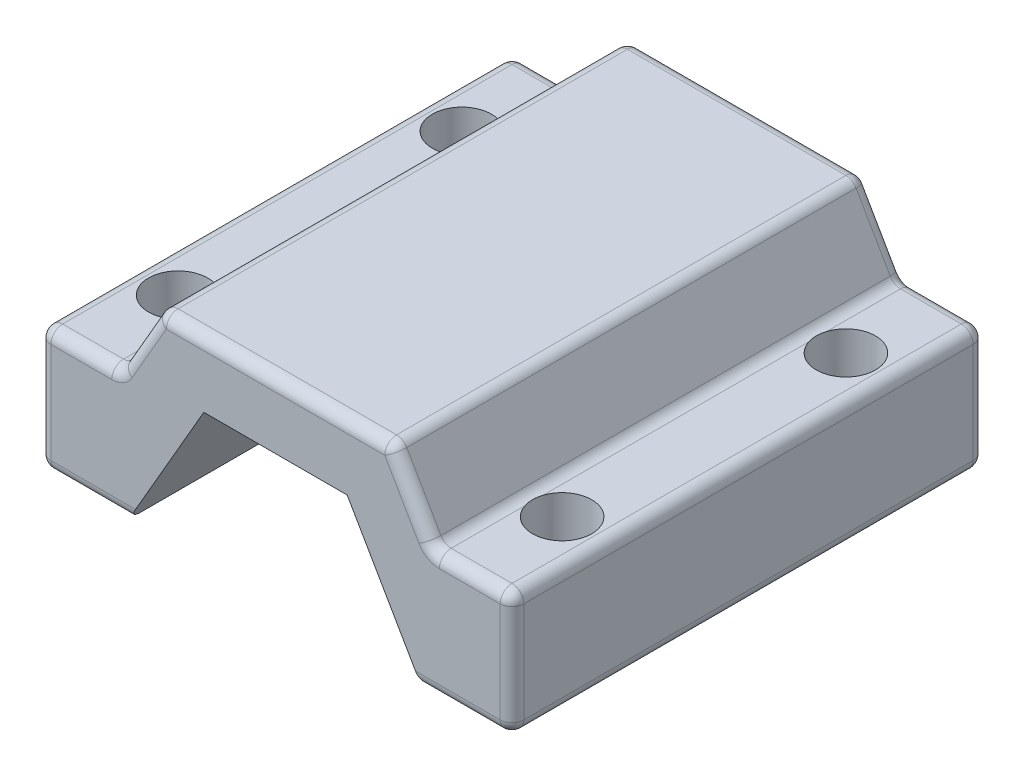
from build123d import *

# Parameters (mm, degrees)
BASE_EXTRUDE_DEPTH                               = 254
CUT_EXTRUDE3_DEPTH                               = 255
FILLET1_R                                        = 6.35
CBORE_FOR_3_4_SOCKET_HEAD_CAP_SCREW1_D           = 19.84248
CBORE_FOR_3_4_SOCKET_HEAD_CAP_SCREW1_CBORE_D     = 31.75
CBORE_FOR_3_4_SOCKET_HEAD_CAP_SCREW1_CBORE_DEPTH = 63.5


with BuildPart() as part:
    # Sketch1 → Base-Extrude (new body)
    with BuildSketch(Plane.XY):
        Polygon((-38.494829198, 73.025), (38.494829198, 73.025), (78.822745501, 3.175), (127, 3.175), (127, 107.95), (-127, 107.95), (-127, 3.175), (-78.822745501, 3.175), align=None)
    extrude(amount=BASE_EXTRUDE_DEPTH)

    # Sketch4 → Cut-Extrude3 (cut, through all)
    with BuildSketch(Plane.XY.offset(254)):
        Polygon((-127, 69.85), (-127, 107.95), (-62.324961559, 107.95), (-84.322006815, 69.85), align=None)
    cut_extrude3 = extrude(amount=-CUT_EXTRUDE3_DEPTH, mode=Mode.SUBTRACT)

    # Mirror1: Cut-Extrude3 across plane
    add(cut_extrude3.mirror(Plane(origin=(0, 0, 0), x_dir=(0, 0, 1), z_dir=(1, 0, 0))), mode=Mode.SUBTRACT)

    # Fillet1
    fillet1_edges = [part.edges().sort_by_distance(p)[0] for p in [
        (127, 36.5125, 0),
        (102.911372751, 3.175, 0),
        (-127, 36.5125, 254),
        (-127, 3.175, 127),
        (127, 3.175, 127),
        (-102.911372751, 3.175, 254),
        (-73.323484187, 88.9, 254),
        (-62.324961559, 107.95, 127),
        (-105.661003408, 69.85, 254),
        (-84.322006815, 69.85, 127),
        (-127, 69.85, 127),
        (-73.323484187, 88.9, 0),
        (-105.661003408, 69.85, 0),
        (0, 107.95, 0),
        (0, 107.95, 254),
        (102.911372751, 3.175, 254),
        (62.324961559, 107.95, 127),
        (105.661003408, 69.85, 0),
        (127, 69.85, 127),
        (73.323484187, 88.9, 0),
        (84.322006815, 69.85, 127),
        (73.323484187, 88.9, 254),
        (105.661003408, 69.85, 254),
        (127, 36.5125, 254),
        (-102.911372751, 3.175, 0),
        (-127, 36.5125, 0),
    ]]
    fillet(fillet1_edges, radius=FILLET1_R)

    # CBORE for 3/4 Socket Head Cap Screw1 (through all)
    with Locations(Plane(origin=(32.15140412, 107.95, 73.186569829), x_dir=(-1, 0, 0), z_dir=(0, 1, 0))):
        with Locations((135.27540412, 130.013430171), (135.27540412, -22.386569829), (-70.97259588, -22.386569829), (-70.97259588, 130.013430171)):
            CounterBoreHole(CBORE_FOR_3_4_SOCKET_HEAD_CAP_SCREW1_D / 2, CBORE_FOR_3_4_SOCKET_HEAD_CAP_SCREW1_CBORE_D / 2, CBORE_FOR_3_4_SOCKET_HEAD_CAP_SCREW1_CBORE_DEPTH)


solid = part.part
